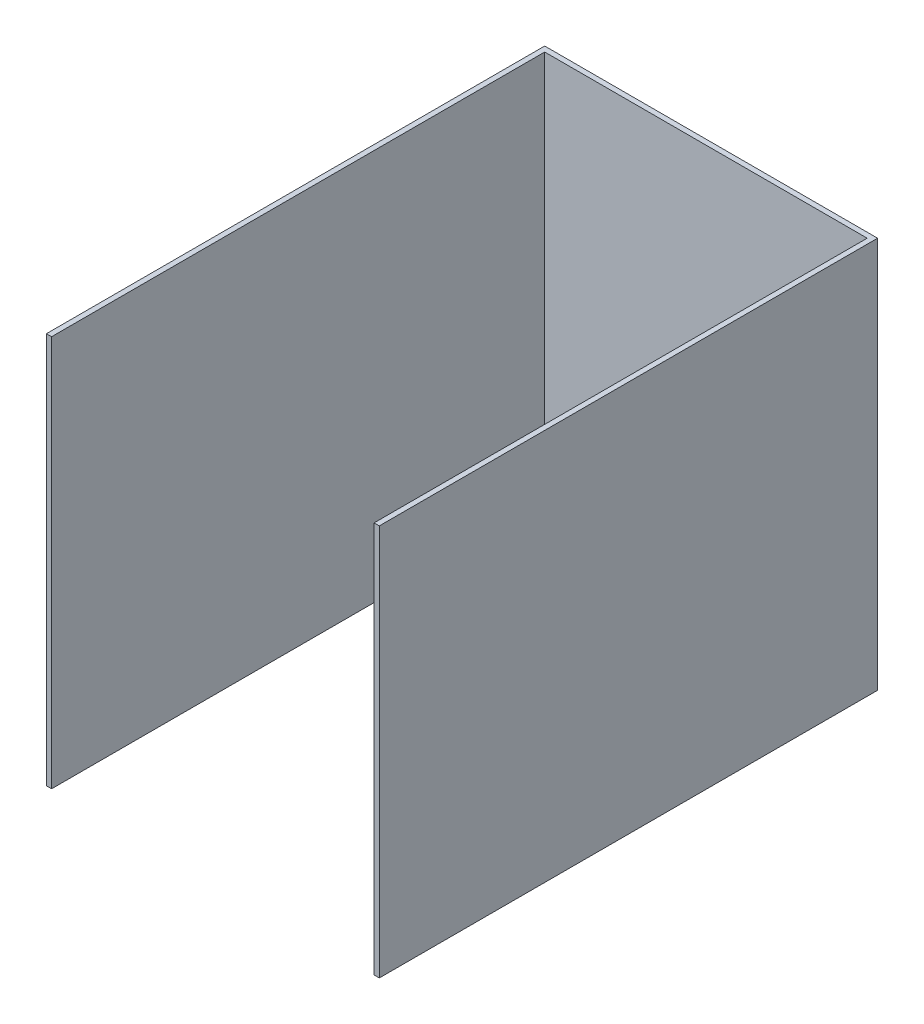
from build123d import *

# Parameters (mm, degrees)
SKETCH1_W           = 203.2
SKETCH1_H           = 239
BOSS_EXTRUDE2_DEPTH = 3.175
SKETCH2_W           = 3.175
SKETCH2_H           = 239
BOSS_EXTRUDE5_DEPTH = 301


with BuildPart() as part:
    # Sketch1 → Boss-Extrude2 (new body)
    with BuildSketch(Plane.XY):
        with Locations((-101.6, 119.5)):
            Rectangle(SKETCH1_W, SKETCH1_H)
    extrude(amount=BOSS_EXTRUDE2_DEPTH)

    # Sketch2 → Boss-Extrude5 (add)
    with BuildSketch(Plane.XY.offset(3.175)):
        with Locations((-201.6125, 119.5)):
            Rectangle(SKETCH2_W, SKETCH2_H)
        with Locations((-1.5875, 119.5)):
            Rectangle(SKETCH2_W, SKETCH2_H)
    extrude(amount=BOSS_EXTRUDE5_DEPTH)


solid = part.part
